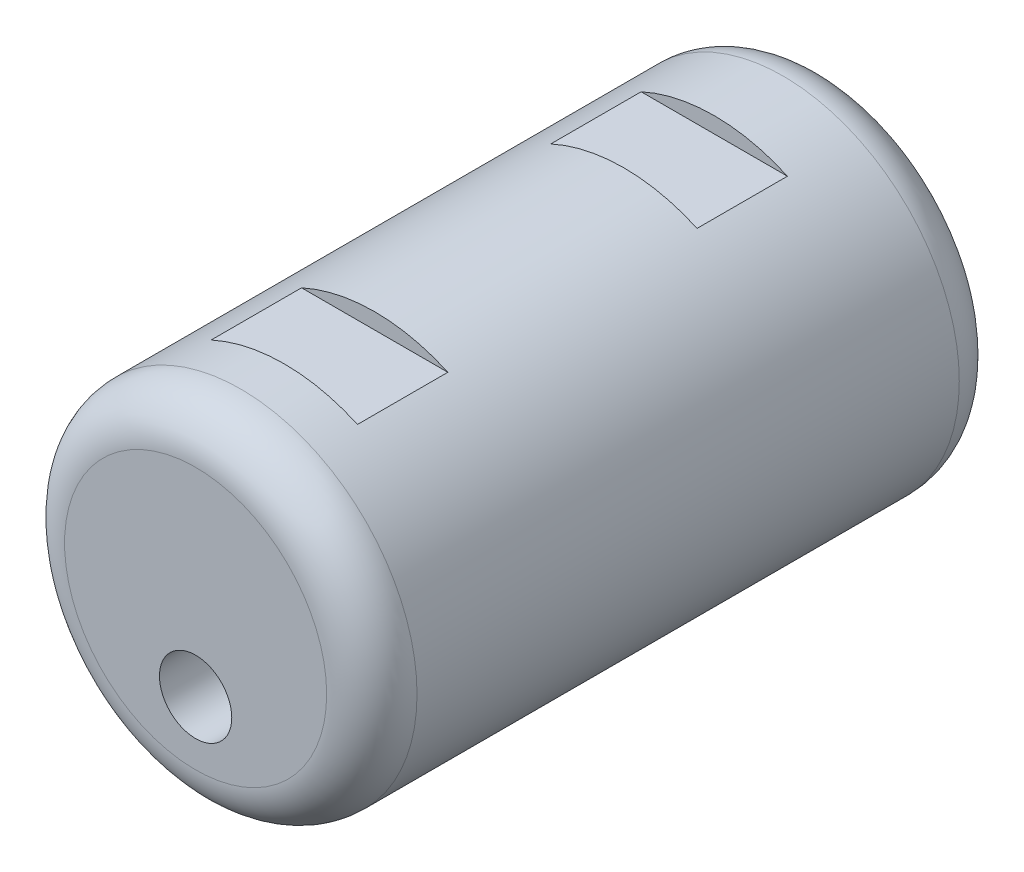
from build123d import *

# Parameters (mm, degrees)
SKETCH1_R               = 3.9
BOSS_EXTRUDE1_DEPTH     = 14
FILLET1_R               = 1
SKETCH2_R               = 0.8
CUT_EXTRUDE1_DEPTH      = 5
CUT_EXTRUDE2_START      = -5
SKETCH3_R               = 0.8
CUT_EXTRUDE2_DEPTH      = 5
CUT_EXTRUDE3_DEPTH      = 5
CUT_EXTRUDE3_DEPTH_BACK = 5
SKETCH4_W               = 2
SKETCH4_H               = 0.351785614
CUT_EXTRUDE4_DEPTH      = 10
CUT_EXTRUDE4_DEPTH_BACK = 10
SKETCH7_W               = 2
SKETCH7_H               = 1.401254955


with BuildPart() as part:
    # Sketch1 → Boss-Extrude1 (new body)
    with BuildSketch(Plane.XY):
        Circle(SKETCH1_R)
    extrude(amount=BOSS_EXTRUDE1_DEPTH)

    # Fillet1
    fillet1_edges = [part.edges().sort_by_distance(p)[0] for p in [
        (-3.9, 0, 14),
        (-3.9, 0, 0),
    ]]
    fillet(fillet1_edges, radius=FILLET1_R)

    # Sketch2 → Cut-Extrude1 (cut)
    with BuildSketch(Plane.XY.offset(14)):
        with Locations((0, -1.5)):
            Circle(SKETCH2_R)
    extrude(amount=-CUT_EXTRUDE1_DEPTH, mode=Mode.SUBTRACT)

    # Sketch3 → Cut-Extrude2 (cut)
    with BuildSketch(Plane(origin=(0, 0, 0), x_dir=(-1, 0, 0), z_dir=(0, 0, -1)).offset(CUT_EXTRUDE2_START)):
        with Locations((0, -1.5)):
            Circle(SKETCH3_R)
    extrude(amount=CUT_EXTRUDE2_DEPTH, mode=Mode.SUBTRACT)

    # Sketch4 → Cut-Extrude3 (cut, two sides: drawn at the far end of the back side and taken through both)
    with BuildSketch(Plane(origin=(0, 0, 0), x_dir=(0, 0, -1), z_dir=(1, 0, 0)).offset(-CUT_EXTRUDE3_DEPTH_BACK)):
        with Locations((-3.521882016, 3.724107193)):
            Rectangle(SKETCH4_W, SKETCH4_H)
    extrude(amount=CUT_EXTRUDE3_DEPTH + CUT_EXTRUDE3_DEPTH_BACK, mode=Mode.SUBTRACT)

    # Sketch7 → Cut-Extrude4 (cut, two sides: drawn at the far end of the back side and taken through both)
    with BuildSketch(Plane(origin=(0, 0, 0), x_dir=(0, 0, -1), z_dir=(1, 0, 0)).offset(-CUT_EXTRUDE4_DEPTH_BACK)):
        with Locations((-11.03673309, 4.248841864)):
            Rectangle(SKETCH7_W, SKETCH7_H)
    extrude(amount=CUT_EXTRUDE4_DEPTH + CUT_EXTRUDE4_DEPTH_BACK, mode=Mode.SUBTRACT)


solid = part.part
